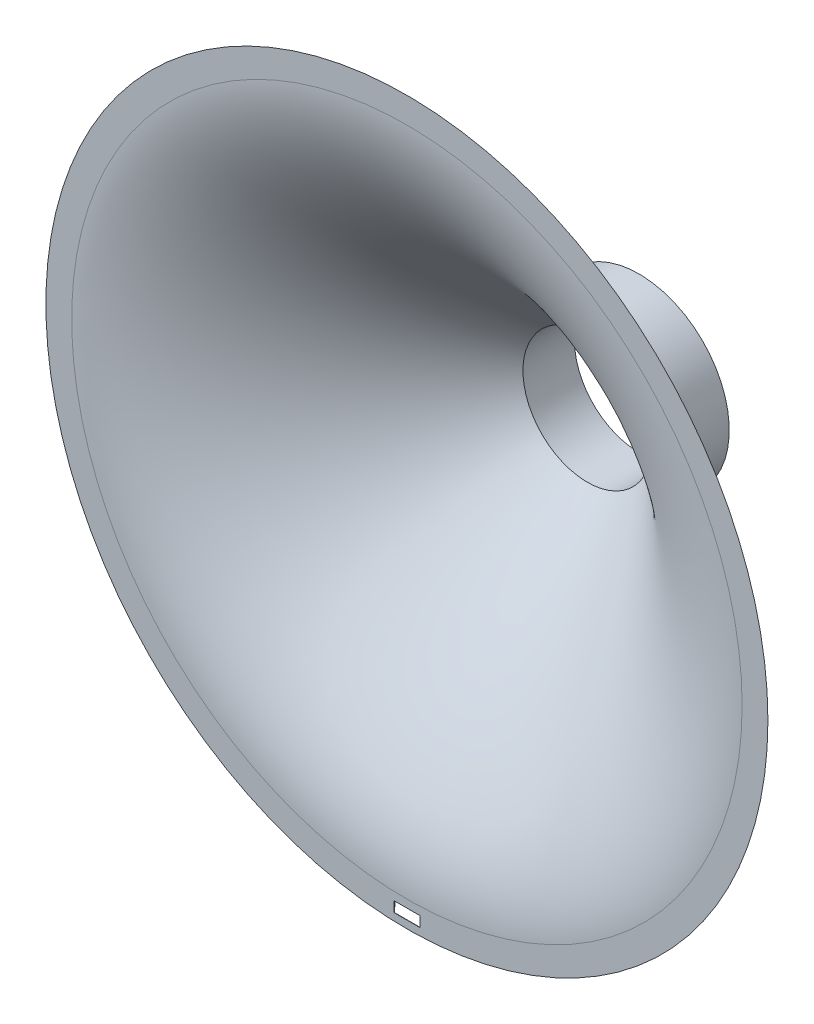
from build123d import *

# Parameters (mm, degrees)
SKETCH2_W           = 5
SKETCH2_H           = 2
CUT_EXTRUDE3_DEPTH  = 10
SKETCH3_R           = 17.5
SKETCH3_R_2         = 12.5
BOSS_EXTRUDE1_DEPTH = 10


with BuildPart() as part:
    # Sketch1 → Revolve1 (revolve)
    with BuildSketch(Plane(origin=(0, 0, 0), x_dir=(0, 0, -1), z_dir=(1, 0, 0))):
        with BuildLine():
            Line((0, 65), (0, 70))
            add(Edge.make_bspline(
                [(0, 70), (0, 52.5), (22.625631329, 29.874368671), (35, 17.5)],
                knots=[0, 0, 0, 0, 1, 1, 1, 1], degree=3))
            Line((35, 17.5), (35, 12.5))
            add(Edge.make_bspline(
                [(0, 65), (0, 47.5), (22.625631329, 24.874368671), (35, 12.5)],
                knots=[0, 0, 0, 0, 1, 1, 1, 1], degree=3))
        make_face()
    revolve(axis=Axis((0, 0, 0), (0, 0, -1)))

    # Sketch2 → Cut-Extrude3 (cut)
    with BuildSketch(Plane.XY):
        with Locations((0, -67.5)):
            Rectangle(SKETCH2_W, SKETCH2_H)
    extrude(amount=-CUT_EXTRUDE3_DEPTH, mode=Mode.SUBTRACT)

    # Sketch3 → Boss-Extrude1 (add)
    with BuildSketch(Plane(origin=(0, 0, -35), x_dir=(-1, 0, 0), z_dir=(0, 0, -1))):
        Circle(SKETCH3_R)
        Circle(SKETCH3_R_2, mode=Mode.SUBTRACT)
    extrude(amount=BOSS_EXTRUDE1_DEPTH)


solid = part.part
